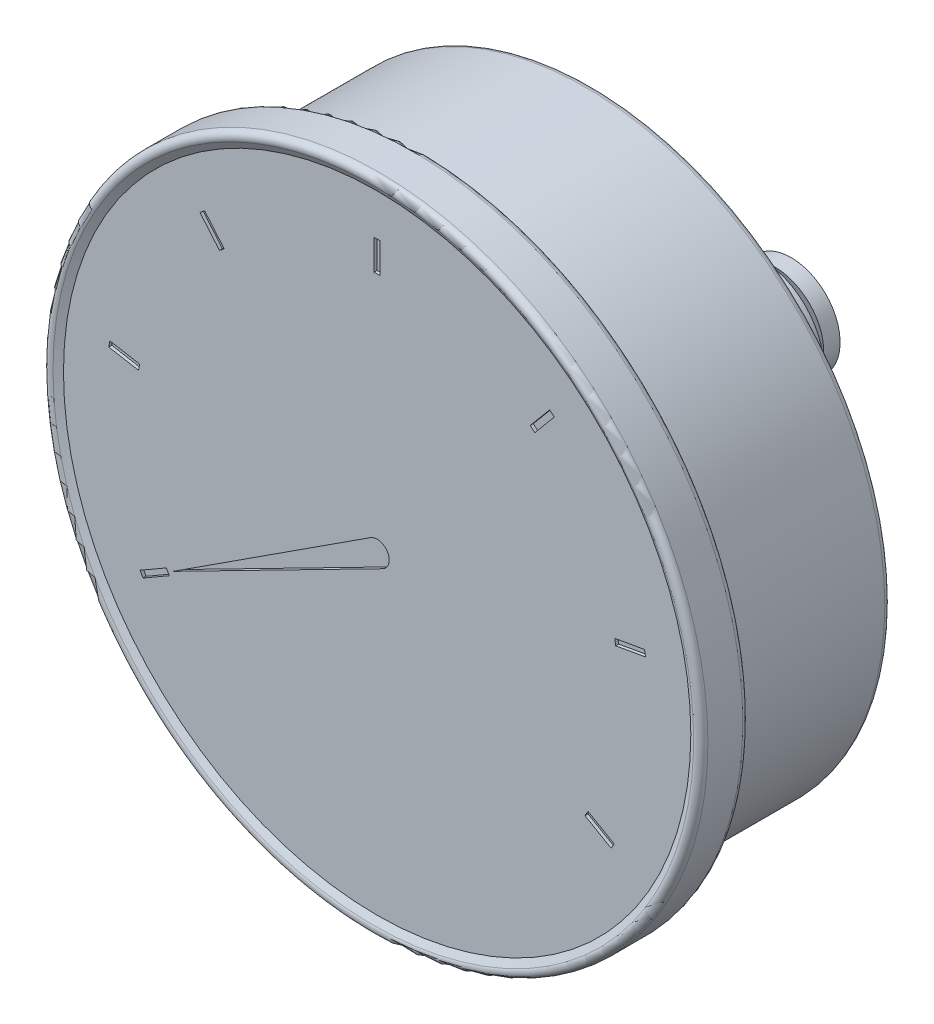
from build123d import *

# Parameters (mm, degrees)
ZAOBLIT1_R               = 1
SKICA2_W                 = 1
SKICA2_H                 = 5
ODEBRAT_VYSUNUT_M1_DEPTH = 0.5
KRUHOV_POLE1_COUNT       = 9
ODEBRAT_VYSUNUT_M2_DEPTH = 0.5
P_IDAT_START             = 13.5
P_IDAT_VYSUNUT_M1_DEPTH  = 3.5
LINPOLE1_COUNT           = 2
LINPOLE1_PITCH           = 6.2


with BuildPart() as part:
    # Skica1 → Rotovat1 (revolve)
    with BuildSketch(Plane(origin=(0, 0, 0), x_dir=(0, 0, -1), z_dir=(1, 0, 0)), mode=Mode.PRIVATE) as rotovat1_sk:
        Polygon((0, 54.5), (1.5, 51.901923789), (1.5, 0), (72.7, 0), (72.7, 2.9), (70, 2.9), (70, 8.1), (67.3, 8.1), (65, 10.4), (37, 10.4), (37, 49.5), (8.5, 49.5), (8.5, 54.5), align=None)
    revolve(rotovat1_sk.sketch.rotate(Axis((0, 0, 0), (0, 0, 1)), 90), axis=Axis((0, 0, 0), (0, 0, 1)))  # turned: the seam where the file's is

    # Zaoblit1
    zaoblit1_edges = [part.edges().sort_by_distance(p)[0] for p in [
        (49.5, 0, -37),
        (54.5, 0, -8.5),
        (54.5, 0, 0),
    ]]
    fillet(zaoblit1_edges, radius=ZAOBLIT1_R)

    # Skica2 → Odebrat vysunutím1 (cut)
    with BuildSketch(Plane.XY.offset(-1.5)):
        with Locations((0, 42.5)):
            Rectangle(SKICA2_W, SKICA2_H)
    odebrat_vysunut_m1 = extrude(amount=-ODEBRAT_VYSUNUT_M1_DEPTH, mode=Mode.SUBTRACT)

    # Kruhové pole1: Odebrat vysunutím1 ×9 about axis, 2 skipped
    kruhov_pole1_axis = Axis((0, 0, 0), (0, 0, -1))
    add([odebrat_vysunut_m1.rotate(kruhov_pole1_axis, i * 360 / KRUHOV_POLE1_COUNT) for i in range(1, KRUHOV_POLE1_COUNT) if i not in (4, 5)], mode=Mode.SUBTRACT)

    # Skica3 → Odebrat vysunutím2 (cut)
    with BuildSketch(Plane.XY.offset(-1.5)):
        with BuildLine():
            Line((-1.087507328, 1.678489741), (-33.774990748, -19.5))
            Line((-33.774990748, -19.5), (0.909861092, -1.781053844))
            ThreePointArc((0.909861092, -1.781053844), (1.732050808, 1), (-1.087507328, 1.678489741))
        make_face()
    extrude(amount=-ODEBRAT_VYSUNUT_M2_DEPTH, mode=Mode.SUBTRACT)

    # Skica4 → Přidat vysunutím1 (add)
    with BuildSketch(Plane(origin=(0, 0, -37), x_dir=(-1, 0, 0), z_dir=(0, 0, -1)).offset(P_IDAT_START)):
        Polygon((0, 12.701705922), (-11, 6.350852961), (-11, -6.350852961), (0, -12.701705922), (11, -6.350852961), (11, 6.350852961), align=None)
    p_idat_vysunut_m1 = extrude(amount=-P_IDAT_VYSUNUT_M1_DEPTH)

    # LinPole1: Přidat vysunutím1 ×2
    with Locations(*[(0, 0, i * LINPOLE1_PITCH) for i in range(1, LINPOLE1_COUNT)]):
        add(p_idat_vysunut_m1)


solid = part.part
